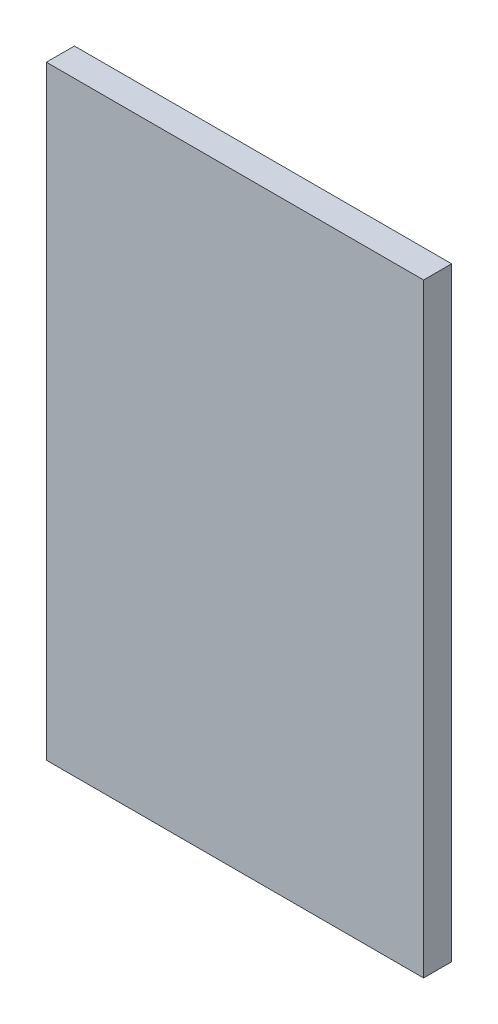
from build123d import *

# Parameters (mm, degrees)
SKETCH1_W           = 78
SKETCH1_H           = 125
BOSS_EXTRUDE1_DEPTH = 5.8


with BuildPart() as part:
    # Sketch1 → Boss-Extrude1 (new body)
    with BuildSketch(Plane.XY):
        Rectangle(SKETCH1_W, SKETCH1_H)
    extrude(amount=-BOSS_EXTRUDE1_DEPTH)


solid = part.part
